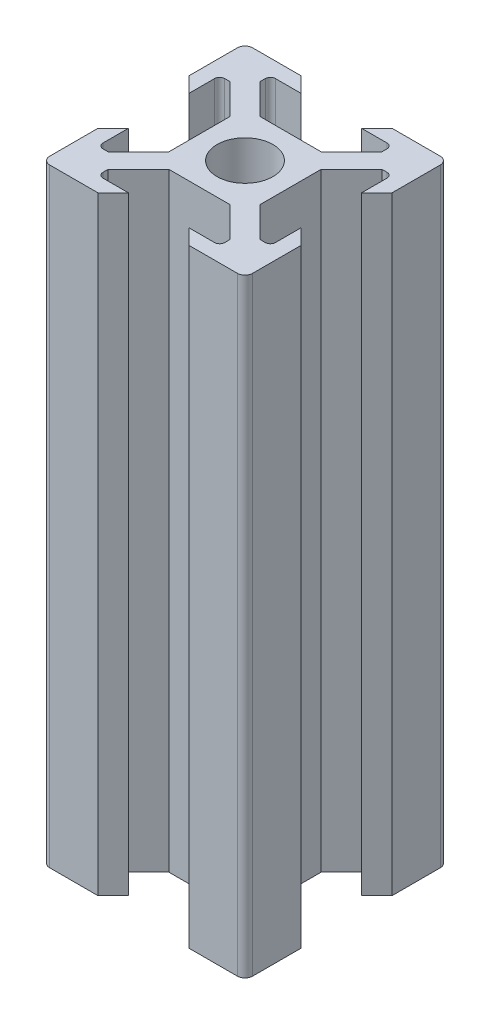
from build123d import *

# Parameters (mm, degrees)
BOSS_EXTRUDE2_DEPTH = 60
SKETCH1_3_R         = 2.75
CUT_EXTRUDE4_DEPTH  = 80
FILLET7_R           = 0.75
FILLET8_R           = 0.5


with BuildPart() as part:
    # Sketch1 → Boss-Extrude2 (new body)
    with BuildSketch(Plane(origin=(0, 0, 0), x_dir=(1, 0, 0), z_dir=(0, 1, 0))):
        Polygon((-3, 4.5), (3, 4.5), (6, 7.5), (6, 8.5), (3, 8.5), (4.5, 10), (10, 10), (10, 4.5), (8.5, 3), (8.5, 6), (7.5, 6), (4.5, 3), (4.5, -3), (7.5, -6), (8.5, -6), (8.5, -3), (10, -4.5), (10, -10), (4.5, -10), (3, -8.5), (6, -8.5), (6, -7.5), (3, -4.5), (-3, -4.5), (-6, -7.5), (-6, -8.5), (-3, -8.5), (-4.5, -10), (-10, -10), (-10, -4.5), (-8.5, -3), (-8.5, -6), (-7.5, -6), (-4.5, -3), (-4.5, 3), (-7.5, 6), (-8.5, 6), (-8.5, 3), (-10, 4.5), (-10, 10), (-4.5, 10), (-3, 8.5), (-6, 8.5), (-6, 7.5), align=None)
    extrude(amount=BOSS_EXTRUDE2_DEPTH)

    # Sketch1_3 → Cut-Extrude4 (cut)
    with BuildSketch(Plane(origin=(0, 0, 0), x_dir=(1, 0, 0), z_dir=(0, 1, 0))):
        Circle(SKETCH1_3_R)
    extrude(amount=CUT_EXTRUDE4_DEPTH, mode=Mode.SUBTRACT)

    # Fillet7
    fillet7_edges = [part.edges().sort_by_distance(p)[0] for p in [
        (-10, 30, 10),
        (10, 30, 10),
        (10, 30, -10),
        (-10, 30, -10),
    ]]
    fillet(fillet7_edges, radius=FILLET7_R)

    # Fillet8
    fillet8_edges = [part.edges().sort_by_distance(p)[0] for p in [
        (-8.5, 30, -6),
        (-6, 30, -8.5),
        (8.5, 30, -6),
        (6, 30, -8.5),
        (8.5, 30, 6),
        (6, 30, 8.5),
        (-6, 30, 8.5),
        (-8.5, 30, 6),
    ]]
    fillet(fillet8_edges, radius=FILLET8_R)


solid = part.part
